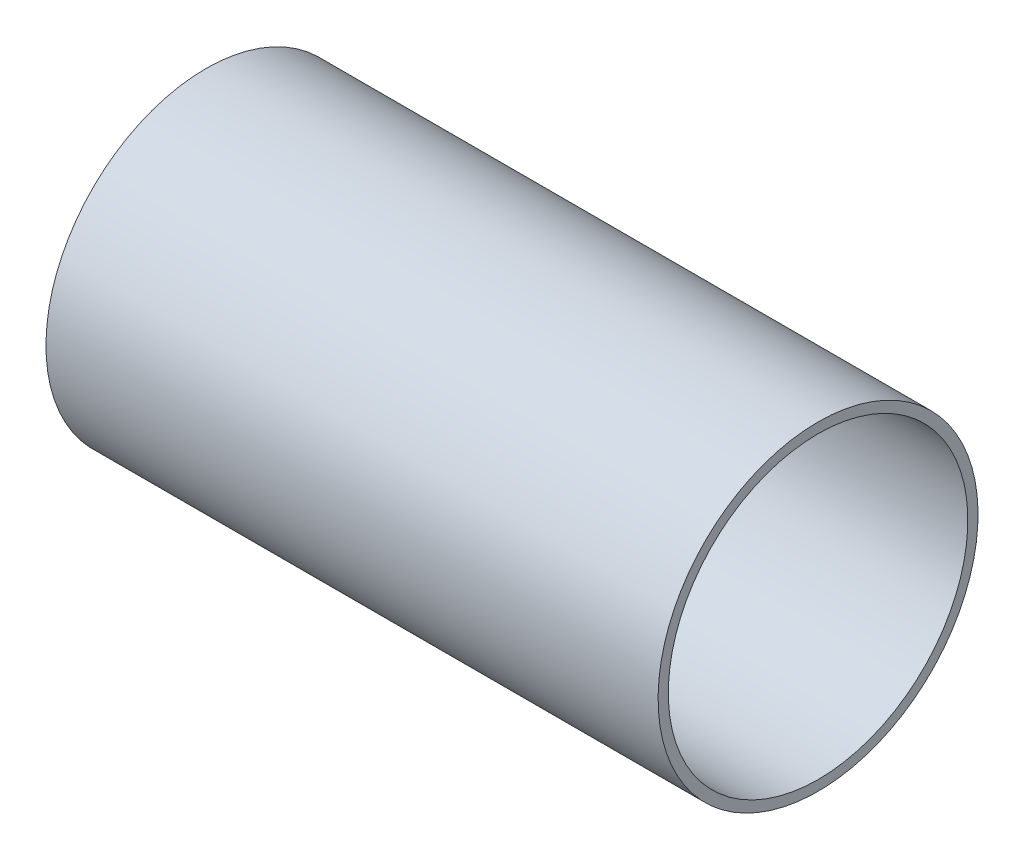
from build123d import *

# Parameters (mm, degrees)
SKETCH2_R           = 49.784
BOSS_EXTRUDE1_DEPTH = 203.2
SKETCH3_R           = 11.74839717
BOSS_EXTRUDE2_DEPTH = 50.8
SKETCH4_R           = 53.885165976
CUT_EXTRUDE1_DEPTH  = 375.969043164
SHELL1_T            = -3.175


with BuildPart() as part:
    # Sketch1 → Revolve1 (revolve)
    with BuildSketch(Plane.XY):
        with BuildLine():
            Line((304.8, 49.784), (304.8, 0))
            Line((304.8, 0), (0, 0))
            Line((0, 0), (0, 11.748397173))
            add(Edge.make_bspline(
                [(0, 11.748397173), (0.424160675, 11.855932678), (1.277768006, 12.07173392), (3.085410505, 12.527272667), (5.106222596, 13.032281093), (7.110128552, 13.529344024), (9.159948224, 14.034387922), (11.195444228, 14.532141119), (13.233412884, 15.026861964), (15.805049223, 15.64653599), (18.91026091, 16.387291474), (22.550652523, 17.244690048), (26.727238439, 18.213147263), (31.952168035, 19.405675489), (42.412897925, 21.742539102), (62.333903875, 25.976370199), (110.770450737, 35.225121195), (160.70732909, 42.159920913), (207.702302928, 46.434962608), (245.168015054, 48.368183749), (253.734807707, 48.740972714), (260.161369668, 48.98354131), (264.446272339, 49.130442523), (268.731666265, 49.262530797), (273.017475857, 49.379804553), (277.303691578, 49.48226239), (281.590188304, 49.569903083), (285.329649653, 49.633426545), (288.521672796, 49.67849525), (291.166731437, 49.70980578), (293.263778354, 49.731088433), (295.359186858, 49.74882407), (297.470177021, 49.76301264), (299.535126271, 49.773654103), (301.617177871, 49.780748429), (303.482211221, 49.783408805), (304.362420109, 49.784), (304.8, 49.784)],
                knots=[0.082917815, 0.082917815, 0.082917815, 0.082917815, 0.082917815, 0.088601511, 0.094285207, 0.099968902, 0.105652598, 0.111336294, 0.11701999, 0.122703686, 0.128387381, 0.140005218, 0.151623054, 0.16324089, 0.174858727, 0.198094396, 0.267801409, 0.383979763, 0.709279153, 0.744132659, 0.778986165, 0.790604, 0.802221836, 0.813839671, 0.825457507, 0.837075342, 0.848693177, 0.860311013, 0.871928848, 0.877612544, 0.883296239, 0.888979935, 0.89466363, 0.900347326, 0.906031021, 0.911714717, 0.917398412, 0.917398412, 0.917398412, 0.917398412, 0.917398412], degree=4))
        make_face()
    revolve(axis=Axis((304.8, 0, 0), (-1, 0, 0)))

    # Sketch2 → Boss-Extrude1 (add)
    with BuildSketch(Plane(origin=(304.8, 0, 0), x_dir=(0, 0, -1), z_dir=(1, 0, 0))):
        with Locations(Location((0, 0, 0), (0, 0, 90))):
            Circle(SKETCH2_R)
    extrude(amount=BOSS_EXTRUDE1_DEPTH)

    # Sketch3 → Boss-Extrude2 (add)
    with BuildSketch(Plane.ZY):
        with Locations(Location((0, 0, 0), (0, 0, 270))):
            Circle(SKETCH3_R)
    extrude(amount=BOSS_EXTRUDE2_DEPTH)

    # Sketch4 → Cut-Extrude1 (cut, through all)
    with BuildSketch(Plane(origin=(317.5, 0, 0), x_dir=(0, 0, -1), z_dir=(1, 0, 0))):
        Circle(SKETCH4_R)
    extrude(amount=-CUT_EXTRUDE1_DEPTH, mode=Mode.SUBTRACT)

    # Shell1
    shell1_openings = [part.faces().sort_by_distance(p)[0] for p in [
        (508, 0, 0),
        (317.5, 0, 0),
    ]]
    offset(amount=SHELL1_T, openings=shell1_openings, kind=Kind.INTERSECTION)


solid = part.part
